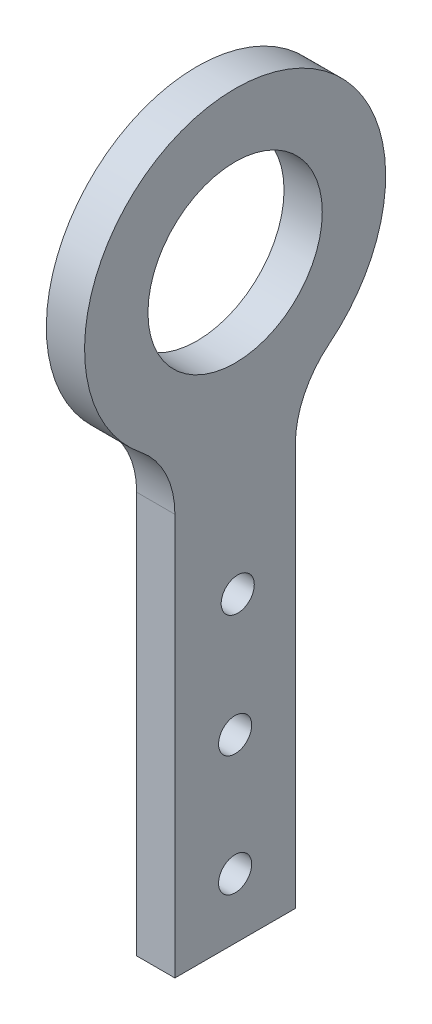
from build123d import *

# Parameters (mm, degrees)
SKETCH1_R           = 14.475
BOSS_EXTRUDE1_DEPTH = 6.35
SKETCH2_R           = 2.75
CUT_EXTRUDE1_DEPTH  = 7.35
FILLET1_R           = 15


with BuildPart() as part:
    # Sketch1 → Boss-Extrude1 (new body)
    with BuildSketch(Plane(origin=(0, 0, 0), x_dir=(0, 0, -1), z_dir=(1, 0, 0))):
        with BuildLine():
            Line((-10, -22.912878475), (-10, -97.912878475))
            Line((-10, -97.912878475), (10, -97.912878475))
            Line((10, -97.912878475), (10, -22.912878475))
            ThreePointArc((10, -22.912878475), (0, 25), (-10, -22.912878475))
        make_face()
        Circle(SKETCH1_R, mode=Mode.SUBTRACT)
    extrude(amount=BOSS_EXTRUDE1_DEPTH)

    # Sketch2 → Cut-Extrude1 (cut, through all)
    with BuildSketch(Plane(origin=(6.35, 0, 0), x_dir=(0, 0, -1), z_dir=(1, 0, 0))):
        with Locations((0, -87.912878475)):
            Circle(SKETCH2_R)
        with Locations((0, -67.912878475)):
            Circle(SKETCH2_R)
        with Locations((0.431184648, -47.912878475)):
            Circle(SKETCH2_R)
    extrude(amount=-CUT_EXTRUDE1_DEPTH, mode=Mode.SUBTRACT)

    # Fillet1
    fillet1_edges = [part.edges().sort_by_distance(p)[0] for p in [
        (3.175, -22.912878475, 10),
        (3.175, -22.912878475, -10),
    ]]
    fillet(fillet1_edges, radius=FILLET1_R)


solid = part.part
